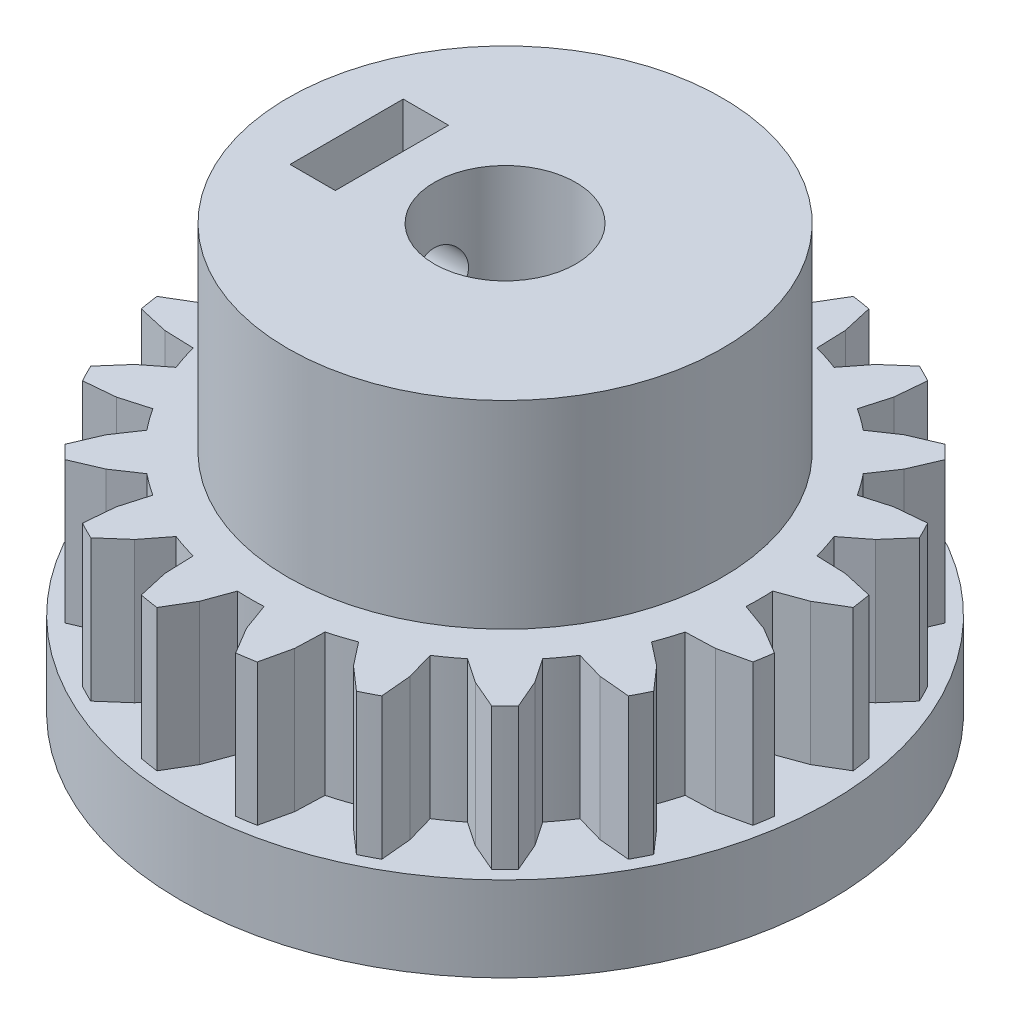
from build123d import *

# Parameters (mm, degrees)
IZIM1_R                     = 11.457141838
Y_KSEKLIK_EKSTR_ZYON1_DEPTH = 3
Y_KSEKLIK_EKSTR_ZYON2_DEPTH = 5
IZIM1_4_R                   = 7.675092559
IZIM1_4_R_2                 = 2.5
Y_KSEKLIK_EKSTR_ZYON3_DEPTH = 12
KES_EKSTR_ZYON3_DEPTH       = 3.1
IZIM4_R                     = 1
KES_EKSTR_ZYON4_DEPTH       = 12.457141838
IZIM6_W                     = 1.6
IZIM6_H                     = 4
KES_EKSTR_ZYON5_DEPTH       = 5


with BuildPart() as part:
    # Çizim1 → Yükseklik-Ekstrüzyon1 (new body)
    with BuildSketch(Plane(origin=(0, 0, 0), x_dir=(1, 0, 0), z_dir=(0, 1, 0))):
        Circle(IZIM1_R)
    extrude(amount=-Y_KSEKLIK_EKSTR_ZYON1_DEPTH)

    # Çizim1<3> → Yükseklik-Ekstrüzyon2 (add)
    with BuildSketch(Plane(origin=(0, 0, 0), x_dir=(1, 0, 0), z_dir=(0, 1, 0))):
        with BuildLine():
            Line((10.911727098, -1.390759414), (9.965743649, -0.827014825))
            Line((9.965743649, -0.827014825), (8.987665813, -0.471023606))
            ThreePointArc((8.987665813, -0.471023606), (9, 0), (8.987665813, 0.471023606))
            Line((8.987665813, 0.471023606), (9.965743649, 0.827014825))
            Line((9.965743649, 0.827014825), (10.911727098, 1.390759414))
            ThreePointArc((10.911727098, 1.390759414), (10.864571747, 1.720779115), (10.807437454, 2.049218308))
            Line((10.807437454, 2.049218308), (9.733547073, 2.29304631))
            Line((9.733547073, 2.29304631), (8.693332437, 2.329371406))
            ThreePointArc((8.693332437, 2.329371406), (8.559508647, 2.781152949), (8.402223838, 3.225311546))
            Line((8.402223838, 3.225311546), (9.222423802, 3.866121988))
            Line((9.222423802, 3.866121988), (9.947900866, 4.694599914))
            ThreePointArc((9.947900866, 4.694599914), (9.801071766, 4.993895497), (9.645240533, 5.288604264))
            Line((9.645240533, 5.288604264), (8.548563091, 5.188648097))
            Line((8.548563091, 5.188648097), (7.548035112, 4.901751315))
            ThreePointArc((7.548035112, 4.901751315), (7.281152949, 5.290067271), (6.994313653, 5.663883519))
            Line((6.994313653, 5.663883519), (7.576348856, 6.526786193))
            Line((7.576348856, 6.526786193), (8.010304787, 7.538900266))
            ThreePointArc((8.010304787, 7.538900266), (7.778174593, 7.778174593), (7.538900266, 8.010304787))
            Line((7.538900266, 8.010304787), (6.526786193, 7.576348856))
            Line((6.526786193, 7.576348856), (5.663883519, 6.994313653))
            ThreePointArc((5.663883519, 6.994313653), (5.290067271, 7.281152949), (4.901751315, 7.548035112))
            Line((4.901751315, 7.548035112), (5.188648097, 8.548563091))
            Line((5.188648097, 8.548563091), (5.288604264, 9.645240533))
            ThreePointArc((5.288604264, 9.645240533), (4.993895497, 9.801071766), (4.694599914, 9.947900866))
            Line((4.694599914, 9.947900866), (3.866121988, 9.222423802))
            Line((3.866121988, 9.222423802), (3.225311546, 8.402223838))
            ThreePointArc((3.225311546, 8.402223838), (2.781152949, 8.559508647), (2.329371406, 8.693332437))
            Line((2.329371406, 8.693332437), (2.29304631, 9.733547073))
            Line((2.29304631, 9.733547073), (2.049218308, 10.807437454))
            ThreePointArc((2.049218308, 10.807437454), (1.720779115, 10.864571747), (1.390759414, 10.911727098))
            Line((1.390759414, 10.911727098), (0.827014825, 9.965743649))
            Line((0.827014825, 9.965743649), (0.471023606, 8.987665813))
            ThreePointArc((0.471023606, 8.987665813), (0, 9), (-0.471023606, 8.987665813))
            Line((-0.471023606, 8.987665813), (-0.827014825, 9.965743649))
            Line((-0.827014825, 9.965743649), (-1.390759414, 10.911727098))
            ThreePointArc((-1.390759414, 10.911727098), (-1.720779115, 10.864571747), (-2.049218308, 10.807437454))
            Line((-2.049218308, 10.807437454), (-2.29304631, 9.733547073))
            Line((-2.29304631, 9.733547073), (-2.329371406, 8.693332437))
            ThreePointArc((-2.329371406, 8.693332437), (-2.781152949, 8.559508647), (-3.225311546, 8.402223838))
            Line((-3.225311546, 8.402223838), (-3.866121988, 9.222423802))
            Line((-3.866121988, 9.222423802), (-4.694599914, 9.947900866))
            ThreePointArc((-4.694599914, 9.947900866), (-4.993895497, 9.801071766), (-5.288604264, 9.645240533))
            Line((-5.288604264, 9.645240533), (-5.188648097, 8.548563091))
            Line((-5.188648097, 8.548563091), (-4.901751315, 7.548035112))
            ThreePointArc((-4.901751315, 7.548035112), (-5.290067271, 7.281152949), (-5.663883519, 6.994313653))
            Line((-5.663883519, 6.994313653), (-6.526786193, 7.576348856))
            Line((-6.526786193, 7.576348856), (-7.538900266, 8.010304787))
            ThreePointArc((-7.538900266, 8.010304787), (-7.778174593, 7.778174593), (-8.010304787, 7.538900266))
            Line((-8.010304787, 7.538900266), (-7.576348856, 6.526786193))
            Line((-7.576348856, 6.526786193), (-6.994313653, 5.663883519))
            ThreePointArc((-6.994313653, 5.663883519), (-7.281152949, 5.290067271), (-7.548035112, 4.901751315))
            Line((-7.548035112, 4.901751315), (-8.548563091, 5.188648097))
            Line((-8.548563091, 5.188648097), (-9.645240533, 5.288604264))
            ThreePointArc((-9.645240533, 5.288604264), (-9.801071766, 4.993895497), (-9.947900866, 4.694599914))
            Line((-9.947900866, 4.694599914), (-9.222423802, 3.866121988))
            Line((-9.222423802, 3.866121988), (-8.402223838, 3.225311546))
            ThreePointArc((-8.402223838, 3.225311546), (-8.559508647, 2.781152949), (-8.693332437, 2.329371406))
            Line((-8.693332437, 2.329371406), (-9.733547073, 2.29304631))
            Line((-9.733547073, 2.29304631), (-10.807437454, 2.049218308))
            ThreePointArc((-10.807437454, 2.049218308), (-10.864571747, 1.720779115), (-10.911727098, 1.390759414))
            Line((-10.911727098, 1.390759414), (-9.965743649, 0.827014825))
            Line((-9.965743649, 0.827014825), (-8.987665813, 0.471023606))
            ThreePointArc((-8.987665813, 0.471023606), (-9, 0), (-8.987665813, -0.471023606))
            Line((-8.987665813, -0.471023606), (-9.965743649, -0.827014825))
            Line((-9.965743649, -0.827014825), (-10.911727098, -1.390759414))
            ThreePointArc((-10.911727098, -1.390759414), (-10.864571747, -1.720779115), (-10.807437454, -2.049218308))
            Line((-10.807437454, -2.049218308), (-9.733547073, -2.29304631))
            Line((-9.733547073, -2.29304631), (-8.693332437, -2.329371406))
            ThreePointArc((-8.693332437, -2.329371406), (-8.559508647, -2.781152949), (-8.402223838, -3.225311546))
            Line((-8.402223838, -3.225311546), (-9.222423802, -3.866121988))
            Line((-9.222423802, -3.866121988), (-9.947900866, -4.694599914))
            ThreePointArc((-9.947900866, -4.694599914), (-9.801071766, -4.993895497), (-9.645240533, -5.288604264))
            Line((-9.645240533, -5.288604264), (-8.548563091, -5.188648097))
            Line((-8.548563091, -5.188648097), (-7.548035112, -4.901751315))
            ThreePointArc((-7.548035112, -4.901751315), (-7.281152949, -5.290067271), (-6.994313653, -5.663883519))
            Line((-6.994313653, -5.663883519), (-7.576348856, -6.526786193))
            Line((-7.576348856, -6.526786193), (-8.010304787, -7.538900266))
            ThreePointArc((-8.010304787, -7.538900266), (-7.778174593, -7.778174593), (-7.538900266, -8.010304787))
            Line((-7.538900266, -8.010304787), (-6.526786193, -7.576348856))
            Line((-6.526786193, -7.576348856), (-5.663883519, -6.994313653))
            ThreePointArc((-5.663883519, -6.994313653), (-5.290067271, -7.281152949), (-4.901751315, -7.548035112))
            Line((-4.901751315, -7.548035112), (-5.188648097, -8.548563091))
            Line((-5.188648097, -8.548563091), (-5.288604264, -9.645240533))
            ThreePointArc((-5.288604264, -9.645240533), (-4.993895497, -9.801071766), (-4.694599914, -9.947900866))
            Line((-4.694599914, -9.947900866), (-3.866121988, -9.222423802))
            Line((-3.866121988, -9.222423802), (-3.225311546, -8.402223838))
            ThreePointArc((-3.225311546, -8.402223838), (-2.781152949, -8.559508647), (-2.329371406, -8.693332437))
            Line((-2.329371406, -8.693332437), (-2.29304631, -9.733547073))
            Line((-2.29304631, -9.733547073), (-2.049218308, -10.807437454))
            ThreePointArc((-2.049218308, -10.807437454), (-1.720779115, -10.864571747), (-1.390759414, -10.911727098))
            Line((-1.390759414, -10.911727098), (-0.827014825, -9.965743649))
            Line((-0.827014825, -9.965743649), (-0.471023606, -8.987665813))
            ThreePointArc((-0.471023606, -8.987665813), (0, -9), (0.471023606, -8.987665813))
            Line((0.471023606, -8.987665813), (0.827014825, -9.965743649))
            Line((0.827014825, -9.965743649), (1.390759414, -10.911727098))
            ThreePointArc((1.390759414, -10.911727098), (1.720779115, -10.864571747), (2.049218308, -10.807437454))
            Line((2.049218308, -10.807437454), (2.29304631, -9.733547073))
            Line((2.29304631, -9.733547073), (2.329371406, -8.693332437))
            ThreePointArc((2.329371406, -8.693332437), (2.781152949, -8.559508647), (3.225311546, -8.402223838))
            Line((3.225311546, -8.402223838), (3.866121988, -9.222423802))
            Line((3.866121988, -9.222423802), (4.694599914, -9.947900866))
            ThreePointArc((4.694599914, -9.947900866), (4.993895497, -9.801071766), (5.288604264, -9.645240533))
            Line((5.288604264, -9.645240533), (5.188648097, -8.548563091))
            Line((5.188648097, -8.548563091), (4.901751315, -7.548035112))
            ThreePointArc((4.901751315, -7.548035112), (5.290067271, -7.281152949), (5.663883519, -6.994313653))
            Line((5.663883519, -6.994313653), (6.526786193, -7.576348856))
            Line((6.526786193, -7.576348856), (7.538900266, -8.010304787))
            ThreePointArc((7.538900266, -8.010304787), (7.778174593, -7.778174593), (8.010304787, -7.538900266))
            Line((8.010304787, -7.538900266), (7.576348856, -6.526786193))
            Line((7.576348856, -6.526786193), (6.994313653, -5.663883519))
            ThreePointArc((6.994313653, -5.663883519), (7.281152949, -5.290067271), (7.548035112, -4.901751315))
            Line((7.548035112, -4.901751315), (8.548563091, -5.188648097))
            Line((8.548563091, -5.188648097), (9.645240533, -5.288604264))
            ThreePointArc((9.645240533, -5.288604264), (9.801071766, -4.993895497), (9.947900866, -4.694599914))
            Line((9.947900866, -4.694599914), (9.222423802, -3.866121988))
            Line((9.222423802, -3.866121988), (8.402223838, -3.225311546))
            ThreePointArc((8.402223838, -3.225311546), (8.559508647, -2.781152949), (8.693332437, -2.329371406))
            Line((8.693332437, -2.329371406), (9.733547073, -2.29304631))
            Line((9.733547073, -2.29304631), (10.807437454, -2.049218308))
            ThreePointArc((10.807437454, -2.049218308), (10.864571747, -1.720779115), (10.911727098, -1.390759414))
        make_face()
    extrude(amount=Y_KSEKLIK_EKSTR_ZYON2_DEPTH)

    # Çizim1<4> → Yükseklik-Ekstrüzyon3 (add)
    with BuildSketch(Plane(origin=(0, 0, 0), x_dir=(1, 0, 0), z_dir=(0, 1, 0))):
        Circle(IZIM1_4_R)
        Circle(IZIM1_4_R_2, mode=Mode.SUBTRACT)
    extrude(amount=Y_KSEKLIK_EKSTR_ZYON3_DEPTH)

    # Çizim3 → Kes-Ekstrüzyon3 (cut)
    with BuildSketch(Plane.XZ.offset(3)):
        Polygon((0.369367692, 1.288138225), (0.300290662, 1.412756488), (0.18649884, 1.3270082), (0.100750552, 1.440800021), (0, 1.340049469), (-0.100750552, 1.440800021), (-0.18649884, 1.3270082), (-0.300290662, 1.412756488), (-0.369367692, 1.288138225), (-0.493985955, 1.357215256), (-0.545047223, 1.224196106), (-0.678066373, 1.275257374), (-0.710118029, 1.136426401), (-0.848949001, 1.168478057), (-0.861367195, 1.026537449), (-1.003307802, 1.038955643), (-0.995850829, 0.896668114), (-1.138138358, 0.88921114), (-1.110951359, 0.749346153), (-1.250816346, 0.722159154), (-1.204428485, 0.587439023), (-1.339148616, 0.541051161), (-1.27446278, 0.414098059), (-1.401415882, 0.349412223), (-1.319691107, 0.232697148), (-1.436406181, 0.150972373), (-1.339233147, 0.046767052), (-1.443438468, -0.050405982), (-1.332708538, -0.140073312), (-1.422375868, -0.250803242), (-1.300244273, -0.324187308), (-1.373628339, -0.446318903), (-1.242472232, -0.501991367), (-1.298144696, -0.633147473), (-1.160516883, -0.670024735), (-1.197394144, -0.807652548), (-1.055973392, -0.825016833), (-1.073337677, -0.966437585), (-0.930876581, -0.963950918), (-0.928389913, -1.106412014), (-0.787661315, -1.084122794), (-0.765372095, -1.224851391), (-0.629115119, -1.183193453), (-0.58745718, -1.31945043), (-0.458323912, -1.259234598), (-0.398108079, -1.388367866), (-0.278611951, -1.310766173), (-0.201010258, -1.430262302), (-0.093477126, -1.336785176), (0, -1.444318308), (0.093477126, -1.336785176), (0.201010258, -1.430262302), (0.278611951, -1.310766173), (0.398108079, -1.388367866), (0.458323912, -1.259234598), (0.58745718, -1.31945043), (0.629115119, -1.183193453), (0.765372095, -1.224851391), (0.787661315, -1.084122794), (0.928389913, -1.106412014), (0.930876581, -0.963950918), (1.073337677, -0.966437585), (1.055973392, -0.825016833), (1.197394144, -0.807652548), (1.160516883, -0.670024735), (1.298144696, -0.633147473), (1.242472232, -0.501991367), (1.373628339, -0.446318903), (1.300244273, -0.324187308), (1.422375868, -0.250803242), (1.332708538, -0.140073312), (1.443438468, -0.050405982), (1.339233147, 0.046767052), (1.436406181, 0.150972373), (1.319691107, 0.232697148), (1.401415882, 0.349412223), (1.27446278, 0.414098059), (1.339148616, 0.541051161), (1.204428485, 0.587439023), (1.250816346, 0.722159154), (1.110951359, 0.749346153), (1.138138358, 0.88921114), (0.995850829, 0.896668114), (1.003307802, 1.038955643), (0.861367195, 1.026537449), (0.848949001, 1.168478057), (0.710118029, 1.136426401), (0.678066373, 1.275257374), (0.545047223, 1.224196106), (0.493985955, 1.357215256), align=None)
    extrude(amount=-KES_EKSTR_ZYON3_DEPTH, mode=Mode.SUBTRACT)

    # Çizim4 → Kes-Ekstrüzyon4 (cut, through all)
    with BuildSketch(Plane(origin=(0, 0, 0), x_dir=(0, 0, -1), z_dir=(1, 0, 0))):
        with Locations((0, 9)):
            Circle(IZIM4_R)
    extrude(amount=-KES_EKSTR_ZYON4_DEPTH, mode=Mode.SUBTRACT)

    # Çizim6 → Kes-Ekstrüzyon5 (cut)
    with BuildSketch(Plane(origin=(0, 12, 0), x_dir=(1, 0, 0), z_dir=(0, 1, 0))):
        with Locations((-4.8, 0)):
            Rectangle(IZIM6_W, IZIM6_H)
    extrude(amount=-KES_EKSTR_ZYON5_DEPTH, mode=Mode.SUBTRACT)


solid = part.part
